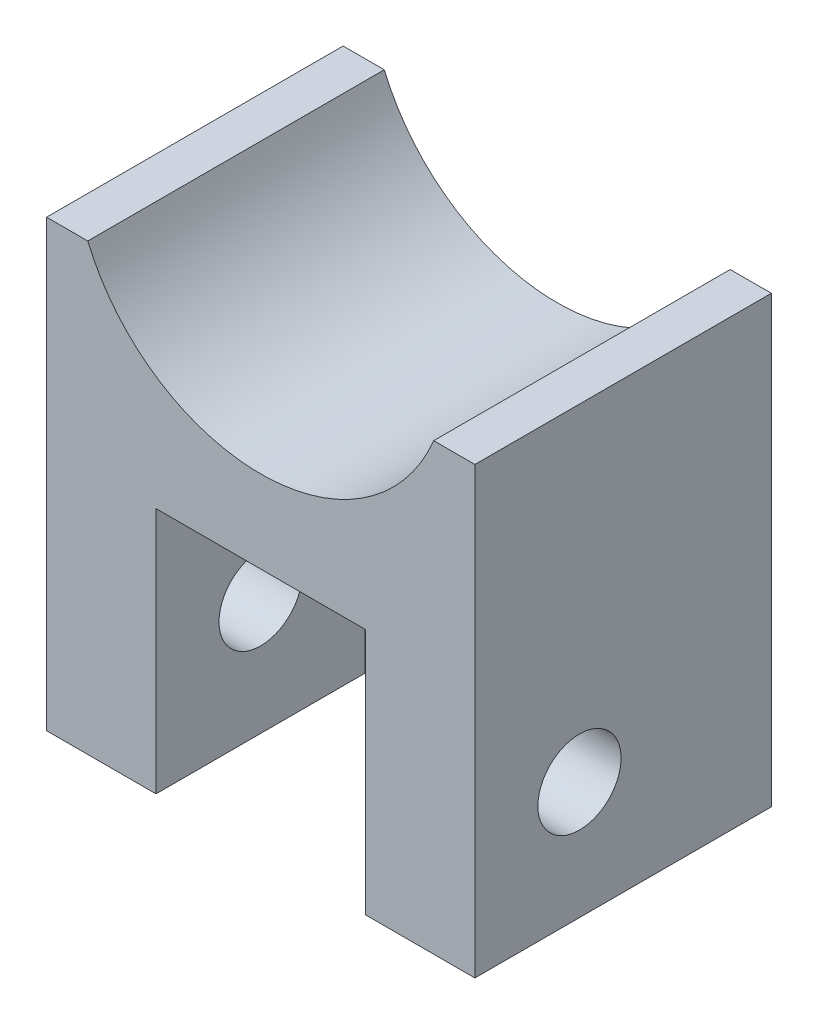
from build123d import *

# Parameters (mm, degrees)
BOSS_EXTRU_1_DEPTH      = 18
ESQUISSE2_W             = 12.72
ESQUISSE2_H             = 15
ENL_V_MAT_EXTRU_1_DEPTH = 12.7
ESQUISSE3_R             = 2.525
ENL_V_MAT_EXTRU_2_DEPTH = 27


with BuildPart() as part:
    # Esquisse1 → Boss.-Extru.1 (new body)
    with BuildSketch(Plane.XY):
        with BuildLine():
            Line((0, 0), (26, 0))
            Line((26, 0), (26, 27))
            Line((26, 27), (23.5, 27))
            ThreePointArc((23.5, 27), (13, 20), (2.5, 27))
            Line((2.5, 27), (0, 27))
            Line((0, 27), (0, 0))
        make_face()
    extrude(amount=BOSS_EXTRU_1_DEPTH)

    # Esquisse2 → Enlèv. mat.-Extru.1 (cut)
    with BuildSketch(Plane.XY.offset(18)):
        with Locations((13, 7.5)):
            Rectangle(ESQUISSE2_W, ESQUISSE2_H)
    extrude(amount=-ENL_V_MAT_EXTRU_1_DEPTH, mode=Mode.SUBTRACT)

    # Esquisse3 → Enlèv. mat.-Extru.2 (cut, through all)
    with BuildSketch(Plane.ZY):
        with Locations((11.65, 7.13)):
            Circle(ESQUISSE3_R)
    extrude(amount=-ENL_V_MAT_EXTRU_2_DEPTH, mode=Mode.SUBTRACT)


solid = part.part
